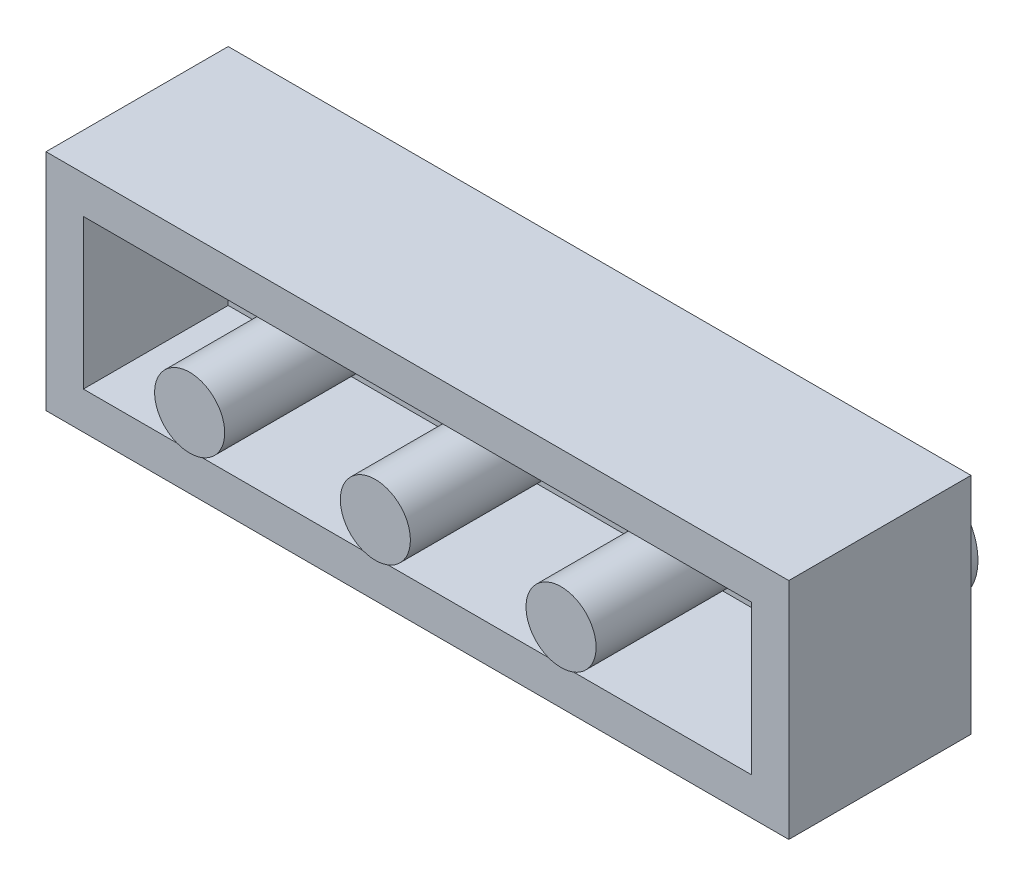
from build123d import *

# Parameters (mm, degrees)
SKETCH1_W           = 31.8
SKETCH1_H           = 7.8
BOSS_EXTRUDE1_DEPTH = 4.8
SHELL2_T            = -1.6
SKETCH2_R           = 2.4
BOSS_EXTRUDE2_DEPTH = 1.8
LPATTERN1_COUNT     = 6
LPATTERN1_PITCH     = 8
SKETCH3_R           = 1.5
BOSS_EXTRUDE3_DEPTH = 8
LPATTERN2_COUNT     = 3
LPATTERN2_PITCH     = 7.95


with BuildPart() as part:
    # Sketch1 → Boss-Extrude1 (new body, symmetric)
    with BuildSketch(Plane(origin=(0, 0, 0), x_dir=(1, 0, 0), z_dir=(0, 1, 0))):
        Rectangle(SKETCH1_W, SKETCH1_H)
    extrude(amount=BOSS_EXTRUDE1_DEPTH, both=True)

    # Shell2
    shell2_openings = [part.faces().sort_by_distance(p)[0] for p in [
        (0, 0, 3.9),
    ]]
    offset(amount=SHELL2_T, openings=shell2_openings, kind=Kind.INTERSECTION)

    # Sketch2 → Boss-Extrude2 (add)
    with BuildSketch(Plane(origin=(0, 0, -3.9), x_dir=(-1, 0, 0), z_dir=(0, 0, -1))):
        with Locations((12, 0)):
            Circle(SKETCH2_R)
    boss_extrude2 = extrude(amount=BOSS_EXTRUDE2_DEPTH)

    # LPattern1: Boss-Extrude2 ×6, 2 skipped
    with Locations(*[(i * LPATTERN1_PITCH, 0, 0) for i in range(1, LPATTERN1_COUNT) if i not in (4, 5)]):
        add(boss_extrude2)

    # Sketch3 → Boss-Extrude3 (add)
    with BuildSketch(Plane.XY.offset(-2.3)):
        with Locations((-7.95, 0)):
            Circle(SKETCH3_R)
    boss_extrude3 = extrude(amount=BOSS_EXTRUDE3_DEPTH)

    # LPattern2: Boss-Extrude3 ×3
    with Locations(*[(i * LPATTERN2_PITCH, 0, 0) for i in range(1, LPATTERN2_COUNT)]):
        add(boss_extrude3)


solid = part.part
